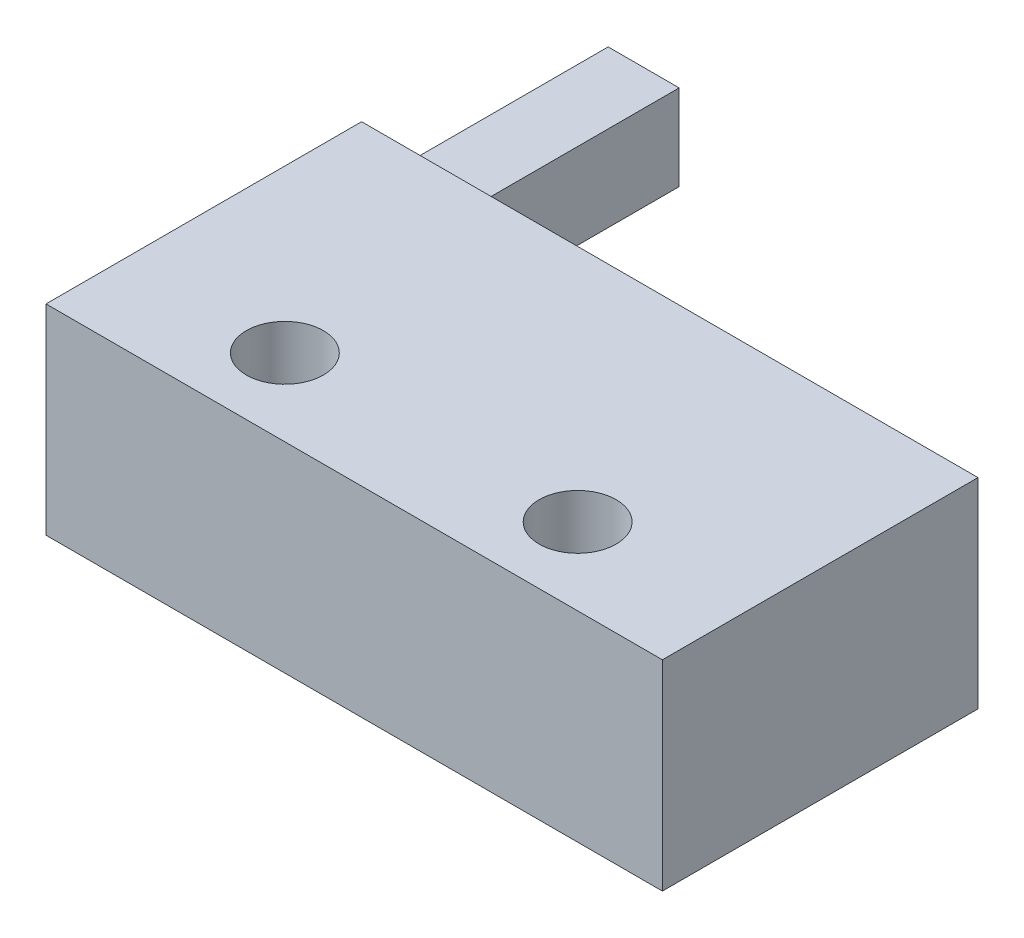
from build123d import *

# Parameters (mm, degrees)
SKETCH_1_W          = 20
SKETCH_1_H          = 10.24
EXTRUDE_1_DEPTH     = 6.5
SKETCH_2_R          = 1.25
CUT_EXTRUDE_1_DEPTH = 7.5
SKETCH_4_W          = 2.303604444
SKETCH_4_H          = 2.775905185
EXTRUDE_2_DEPTH     = 8


with BuildPart() as part:
    # 草图1 → 凸台-拉伸1 (new body)
    with BuildSketch(Plane(origin=(0, 0, 0), x_dir=(1, 0, 0), z_dir=(0, 1, 0))):
        Rectangle(SKETCH_1_W, SKETCH_1_H)
    extrude(amount=EXTRUDE_1_DEPTH)

    # 草图2 → 切除-拉伸1 (cut, through all)
    with BuildSketch(Plane(origin=(0, 6.5, 0), x_dir=(1, 0, 0), z_dir=(0, 1, 0))):
        with Locations((-4.75, -2.62)):
            Circle(SKETCH_2_R)
        with Locations((4.75, -2.62)):
            Circle(SKETCH_2_R)
    extrude(amount=-CUT_EXTRUDE_1_DEPTH, mode=Mode.SUBTRACT)

    # 草图4 → 凸台-拉伸2 (add)
    with BuildSketch(Plane(origin=(0, 0, -5.12), x_dir=(-1, 0, 0), z_dir=(0, 0, -1))):
        with Locations((8.848197778, 3.213855402)):
            Rectangle(SKETCH_4_W, SKETCH_4_H)
    extrude(amount=EXTRUDE_2_DEPTH)


solid = part.part
